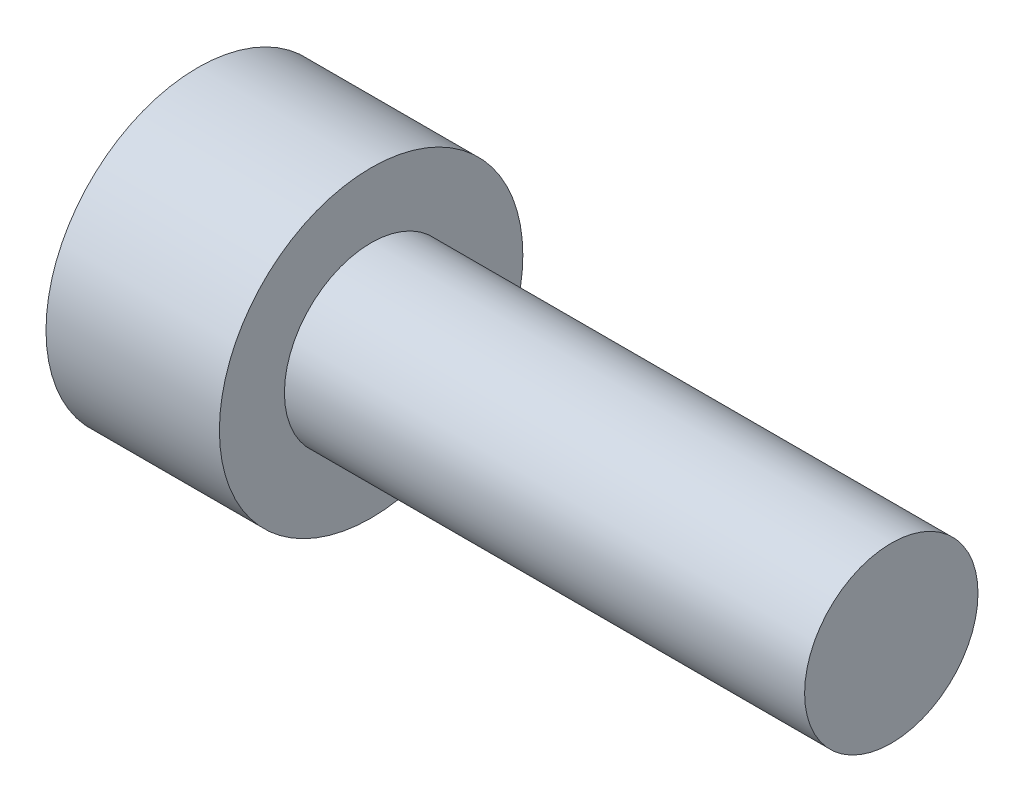
from build123d import *

# Parameters (mm, degrees)
WYTNIJ_WYCI_GNI_CIE1_DEPTH = 2


with BuildPart() as part:
    # Szkic1 → Obrót1 (revolve)
    with BuildSketch(Plane.XY):
        Polygon((0, 0), (0, 3.5), (4, 3.5), (4, 2), (16, 2), (16, 0), align=None)
    revolve(axis=Axis((16, 0, 0), (-1, 0, 0)))

    # Szkic2 → Wytnij-wyciągnięcie1 (cut)
    with BuildSketch(Plane.ZY):
        Polygon((-0.866025404, -1.5), (0.866025404, -1.5), (1.732050808, 0), (0.866025404, 1.5), (-0.866025404, 1.5), (-1.732050808, 0), align=None)
    extrude(amount=-WYTNIJ_WYCI_GNI_CIE1_DEPTH, mode=Mode.SUBTRACT)


solid = part.part
